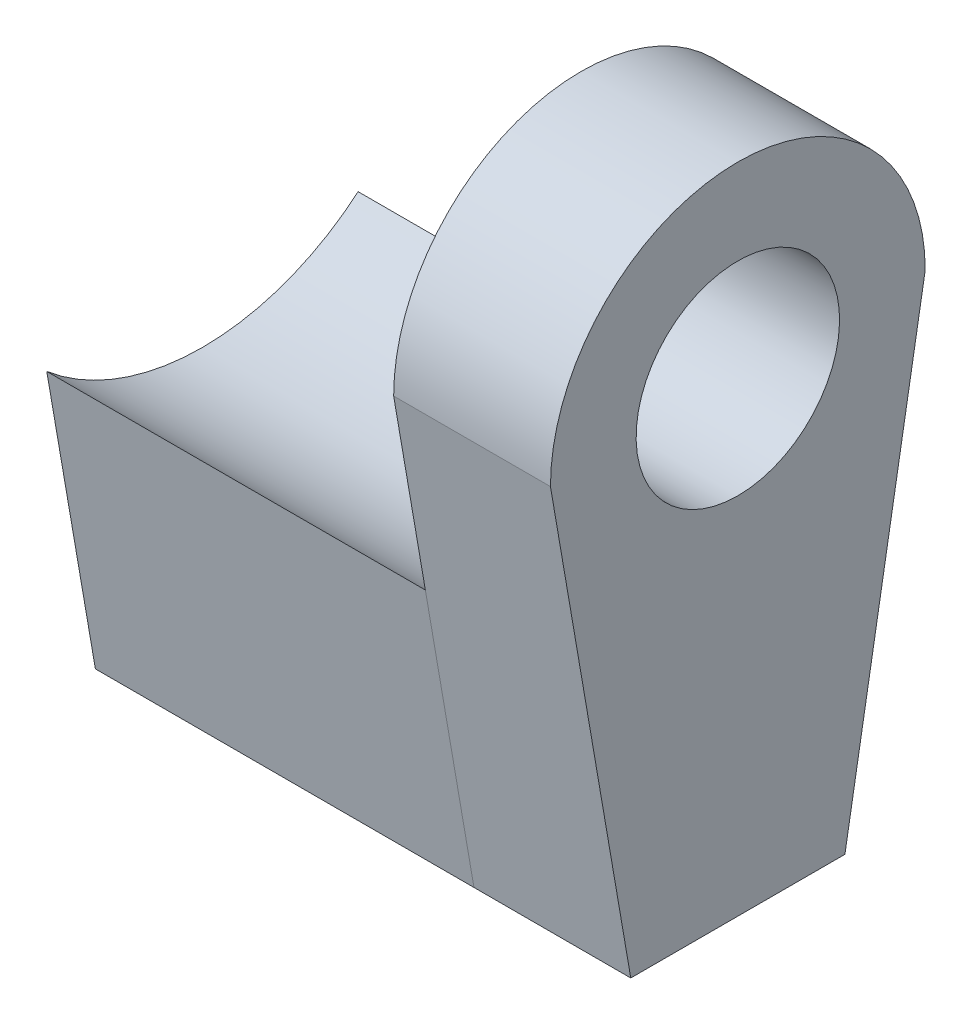
from build123d import *

# Parameters (mm, degrees)
SKETCH1_R           = 1.9
BOSS_EXTRUDE1_DEPTH = 25
BOSS_EXTRUDE2_DEPTH = 51
SKETCH3_R           = 1.51
BOSS_EXTRUDE3_DEPTH = 25
SKETCH7_R           = 1.9
CUT_EXTRUDE4_DEPTH  = 102
SKETCH5_W           = 12.980873034
SKETCH5_H           = 17.196083227
CUT_EXTRUDE2_DEPTH  = 23.071112118
SKETCH6_W           = 13.016891784
SKETCH6_H           = 16.574206387
CUT_EXTRUDE3_DEPTH  = 69.928887882


with BuildPart() as part:
    # Sketch1 → Boss-Extrude1 (new body)
    with BuildSketch(Plane(origin=(0, 0, 0), x_dir=(0, 0, -1), z_dir=(1, 0, 0))):
        with BuildLine():
            Line((2, -8.7), (3.5, 0))
            ThreePointArc((3.5, 0), (0, 3.5), (-3.5, 0))
            Line((-3.5, 0), (-2, -8.7))
            Line((-2, -8.7), (2, -8.7))
        make_face()
        Circle(SKETCH1_R, mode=Mode.SUBTRACT)
    extrude(amount=BOSS_EXTRUDE1_DEPTH)

    # Sketch2 → Boss-Extrude2 (add)
    with BuildSketch(Plane(origin=(25, 0, 0), x_dir=(0, 0, -1), z_dir=(1, 0, 0))):
        with BuildLine():
            Line((-2, -8.7), (2, -8.7))
            Line((2, -8.7), (2.907884559, -3.434269557))
            ThreePointArc((2.907884559, -3.434269557), (0, -4.5), (-2.907884559, -3.434269557))
            Line((-2.907884559, -3.434269557), (-2, -8.7))
        make_face()
    extrude(amount=BOSS_EXTRUDE2_DEPTH)

    # Sketch6 → Cut-Extrude3 (cut, through all)
    with BuildSketch(Plane(origin=(68.928887882, 16.9, 1.27), x_dir=(0, 0, 1), z_dir=(1, 0, 0))):
        with Locations((-1.27, 20.639393127)):
            Rectangle(SKETCH6_W, SKETCH6_H)
    extrude(amount=-CUT_EXTRUDE3_DEPTH, mode=Mode.SUBTRACT)


with BuildPart() as body_2:
    # Sketch3 → Boss-Extrude3 (new body)
    with BuildSketch(Plane(origin=(76, 0, 0), x_dir=(0, 0, -1), z_dir=(1, 0, 0))):
        with BuildLine():
            Line((-3.5, 0), (-2, -8.7))
            Line((-2, -8.7), (2, -8.7))
            Line((2, -8.7), (3.5, 0))
            ThreePointArc((3.5, 0), (0, 3.5), (-3.5, 0))
        make_face()
        Circle(SKETCH3_R, mode=Mode.SUBTRACT)
    extrude(amount=BOSS_EXTRUDE3_DEPTH)

    # Sketch7 → Cut-Extrude4 (cut, through all)
    with BuildSketch(Plane(origin=(101, 0, 0), x_dir=(0, 0, -1), z_dir=(1, 0, 0))):
        Circle(SKETCH7_R)
    extrude(amount=-CUT_EXTRUDE4_DEPTH, mode=Mode.SUBTRACT)

    # Sketch5 → Cut-Extrude2 (cut, through all)
    with BuildSketch(Plane(origin=(78.928887882, 16.9, 1.27), x_dir=(0, 0, 1), z_dir=(1, 0, 0))):
        with Locations((-1.27, 20.925501883)):
            Rectangle(SKETCH5_W, SKETCH5_H)
    extrude(amount=CUT_EXTRUDE2_DEPTH, mode=Mode.SUBTRACT)


solid = Compound([part.part, body_2.part])
